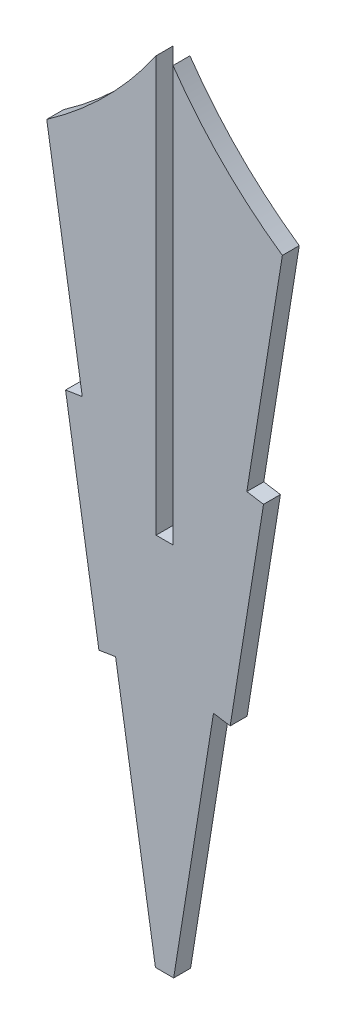
from build123d import *

# Parameters (mm, degrees)
BOSS_EXTRUDE1_DEPTH = 1.524


with BuildPart() as part:
    # Sketch1 → Boss-Extrude1 (new body)
    with BuildSketch(Plane.XY):
        with BuildLine():
            Line((0, -185.062075144), (-1.524, -185.062075144))
            Line((-1.524, -185.062075144), (-1.524, -147.624689716))
            ThreePointArc((-1.524, -147.624689716), (-6.010146882, -153.015597415), (-11.384626883, -157.521411923))
            Line((-11.384626883, -157.521411923), (-8.18166696, -177.565293098))
            Line((-8.18166696, -177.565293098), (-9.686574021, -177.80577332))
            Line((-9.686574021, -177.80577332), (-6.680571239, -196.617111584))
            Line((-6.680571239, -196.617111584), (-5.175664178, -196.376631362))
            Line((-5.175664178, -196.376631362), (-1.585117021, -218.846004156))
            Line((-1.585117021, -218.846004156), (0.061117021, -218.846004156))
            Line((0.061117021, -218.846004156), (3.651664178, -196.376631362))
            Line((3.651664178, -196.376631362), (5.156571239, -196.617111584))
            Line((5.156571239, -196.617111584), (8.162574021, -177.80577332))
            Line((8.162574021, -177.80577332), (6.65766696, -177.565293098))
            Line((6.65766696, -177.565293098), (9.860626883, -157.521411923))
            ThreePointArc((9.860626883, -157.521411923), (4.486146882, -153.015597415), (0, -147.624689716))
            Line((0, -147.624689716), (0, -185.062075144))
        make_face()
    extrude(amount=BOSS_EXTRUDE1_DEPTH)


solid = part.part
